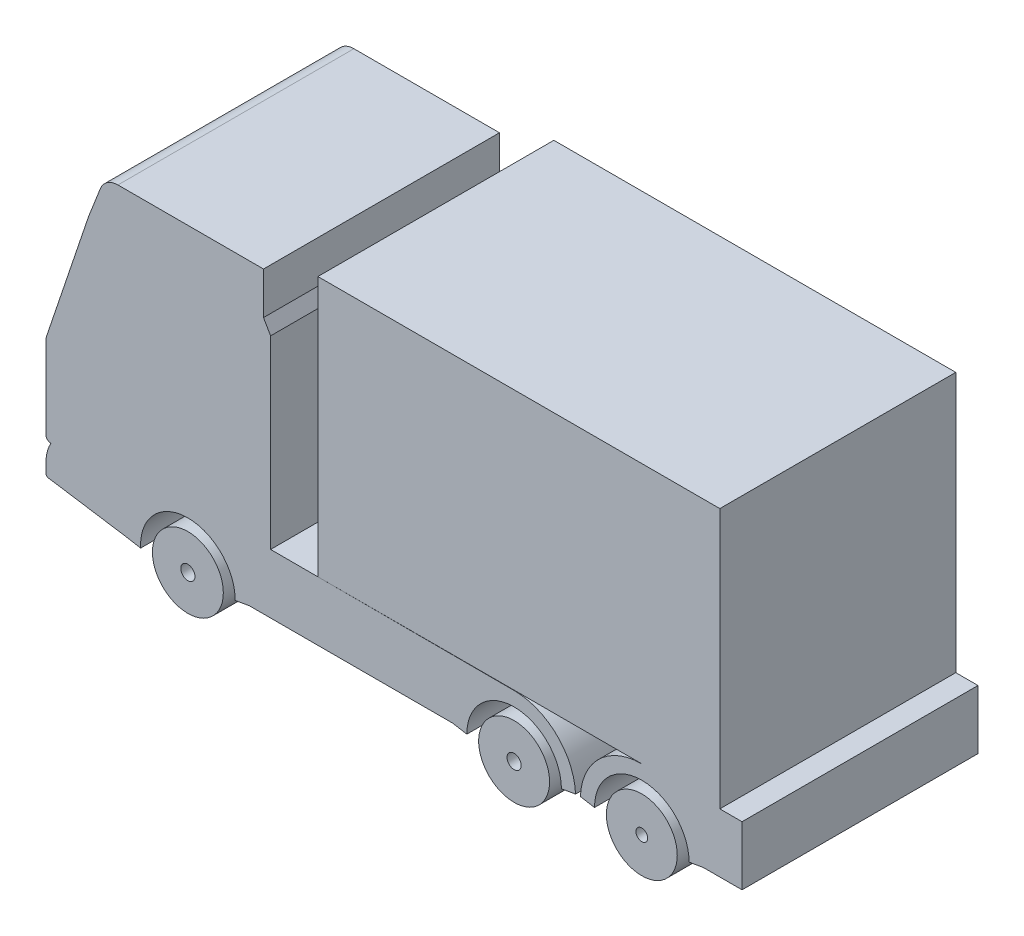
from build123d import *

# Parameters (mm, degrees)
BOSS_EXTRUDE1_DEPTH   = 2495
BOSS_EXTRUDE1_2_DEPTH = 2495
SKETCH1_R             = 375
SKETCH1_R_2           = 75
BOSS_EXTRUDE1_3_DEPTH = 2495
BOSS_EXTRUDE1_4_DEPTH = 2495
SKETCH1_R_3           = 62.5
BOSS_EXTRUDE1_5_DEPTH = 2495


with BuildPart() as part:
    # Sketch1 → Boss-Extrude1 (new body)
    with BuildSketch(Plane.XY):
        with BuildLine():
            Line((2875, 1028.456085172), (2375, 1029.28887678))
            Line((2375, 1029.28887678), (2375, 2985.096189432))
            Line((2375, 2985.096189432), (2300, 3115))
            Line((2300, 3115), (2300, 3560))
            Line((2300, 3560), (760.690046026, 3560))
            ThreePointArc((760.690046026, 3560), (645.974758755, 3523.830408858), (572.751521868, 3428.404028665))
            Line((572.751521868, 3428.404028665), (450, 3115))
            Line((450, 3115), (8.123515112, 1803.669160936))
            ThreePointArc((8.123515112, 1803.669160936), (2.044816358, 1779.658864628), (0, 1754.975598365))
            Line((0, 1754.975598365), (0, 890))
            ThreePointArc((0, 890), (15.425994412, 853.880225117), (52.185525503, 840.047788054))
            ThreePointArc((52.185525503, 840.047788054), (13.266377335, 744.66224526), (0, 642.500094242))
            Line((0, 642.500094242), (0, 538.353176878))
            ThreePointArc((0, 538.353176878), (7.219407149, 518.832813424), (25.402972623, 508.707480069))
            Line((25.402972623, 508.707480069), (850, 380.84085801))
            Line((850, 380.84085801), (1000.706658241, 354.26720799))
            ThreePointArc((1000.706658241, 354.26720799), (1489.850237153, 880.73782971), (1999.960496077, 374.555767537))
            Line((1999.960496077, 374.555767537), (2149.688652822, 400.956881343))
            Line((2149.688652822, 400.956881343), (4300.518483472, 400.956881343))
            Line((4300.518483472, 400.956881343), (4450, 375))
            ThreePointArc((4450, 375), (4950, 875), (5450, 375))
            Line((5450, 375), (5599.481516528, 400.956881343))
            ThreePointArc((5599.481516528, 400.956881343), (5400.348768804, 843.706716867), (4950, 1025))
            Line((4950, 1025), (2875, 1028.456085172))
        make_face()
        with BuildLine():
            Line((1512.224153378, 1030.725901748), (1489.940783681, 1030.763016555))
            ThreePointArc((1489.940783681, 1030.763016555), (1501.082627588, 1030.839956408), (1512.224153378, 1030.725901748))
        make_face(mode=Mode.SUBTRACT)
    extrude(amount=BOSS_EXTRUDE1_DEPTH)


with BuildPart() as body_2:
    # Sketch1 → Boss-Extrude1 2 (new body)
    with BuildSketch(Plane.XY):
        with BuildLine():
            Line((2875, 3778.456085172), (2875, 1028.456085172))
            Line((2875, 1028.456085172), (6300, 1028.456085172))
            ThreePointArc((6300, 1028.456085172), (5849.651231196, 847.162802039), (5650.518483472, 404.412966515))
            Line((5650.518483472, 404.412966515), (5800, 378.456085172))
            ThreePointArc((5800, 378.456085172), (6300, 878.456085172), (6800, 378.456085172))
            Line((6800, 378.456085172), (6949.481516528, 404.412966515))
            Line((6949.481516528, 404.412966515), (7360, 404.412966515))
            Line((7360, 404.412966515), (7360, 1028.456085172))
            Line((7360, 1028.456085172), (7125, 1028.456085172))
            Line((7125, 1028.456085172), (7125, 3778.456085172))
            Line((7125, 3778.456085172), (2875, 3778.456085172))
        make_face()
    extrude(amount=BOSS_EXTRUDE1_2_DEPTH)


with BuildPart() as body_3:
    # Sketch1 → Boss-Extrude1 3 (new body)
    with BuildSketch(Plane.XY):
        with Locations((1500, 380.84085801)):
            Circle(SKETCH1_R)
        with Locations((1500, 380.84085801)):
            Circle(SKETCH1_R_2, mode=Mode.SUBTRACT)
    extrude(amount=BOSS_EXTRUDE1_3_DEPTH)


with BuildPart() as body_4:
    # Sketch1 → Boss-Extrude1 4 (new body)
    with BuildSketch(Plane.XY):
        with Locations((4950, 375)):
            Circle(SKETCH1_R)
        with Locations((4950, 375)):
            Circle(SKETCH1_R_2, mode=Mode.SUBTRACT)
    extrude(amount=BOSS_EXTRUDE1_4_DEPTH)


with BuildPart() as body_5:
    # Sketch1 → Boss-Extrude1 5 (new body)
    with BuildSketch(Plane.XY):
        with Locations((6300, 378.456085172)):
            Circle(SKETCH1_R)
        with Locations((6300, 378.456085172)):
            Circle(SKETCH1_R_3, mode=Mode.SUBTRACT)
    extrude(amount=BOSS_EXTRUDE1_5_DEPTH)


solid = Compound([part.part, body_2.part, body_3.part, body_4.part, body_5.part])
